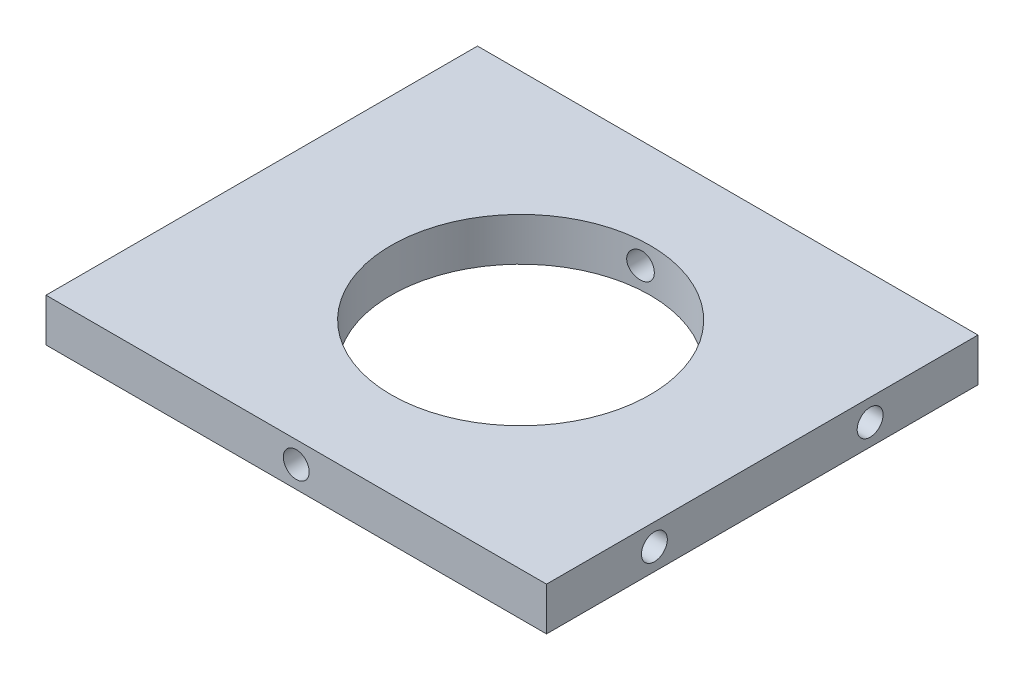
from build123d import *

# Parameters (mm, degrees)
ESQUISSE1_W             = 58
ESQUISSE1_H             = 5
BOSS_EXTRU_1_DEPTH      = 50
ESQUISSE2_R             = 15
ENL_V_MAT_EXTRU_1_DEPTH = 6
ESQUISSE3_R             = 1.5
ENL_V_MAT_EXTRU_2_DEPTH = 10
ESQUISSE4_R             = 1.5
ENL_V_MAT_EXTRU_3_DEPTH = 10
ESQUISSE5_R             = 1.5
ENL_V_MAT_EXTRU_4_DEPTH = 51


with BuildPart() as part:
    # Esquisse1 → Boss.-Extru.1 (new body)
    with BuildSketch(Plane.XY):
        with Locations((23.5, -47.5)):
            Rectangle(ESQUISSE1_W, ESQUISSE1_H)
    extrude(amount=BOSS_EXTRU_1_DEPTH)

    # Esquisse2 → Enlèv. mat.-Extru.1 (cut, through all)
    with BuildSketch(Plane(origin=(0, -45, 0), x_dir=(-1, 0, 0), z_dir=(0, 1, 0))):
        with Locations((-24.5, 25)):
            Circle(ESQUISSE2_R)
    extrude(amount=-ENL_V_MAT_EXTRU_1_DEPTH, mode=Mode.SUBTRACT)

    # Esquisse3 → Enlèv. mat.-Extru.2 (cut)
    with BuildSketch(Plane.ZY.offset(5.5)):
        with Locations((12.5, -47.5)):
            Circle(ESQUISSE3_R)
        with Locations((37.5, -47.5)):
            Circle(ESQUISSE3_R)
    extrude(amount=-ENL_V_MAT_EXTRU_2_DEPTH, mode=Mode.SUBTRACT)

    # Esquisse4 → Enlèv. mat.-Extru.3 (cut)
    with BuildSketch(Plane(origin=(52.5, 0, 0), x_dir=(0, 0, -1), z_dir=(1, 0, 0))):
        with Locations((-37.5, -47.5)):
            Circle(ESQUISSE4_R)
        with Locations((-12.5, -47.5)):
            Circle(ESQUISSE4_R)
    extrude(amount=-ENL_V_MAT_EXTRU_3_DEPTH, mode=Mode.SUBTRACT)

    # Esquisse5 → Enlèv. mat.-Extru.4 (cut, through all)
    with BuildSketch(Plane.XY.offset(50)):
        with Locations((23.5, -47.5)):
            Circle(ESQUISSE5_R)
    extrude(amount=-ENL_V_MAT_EXTRU_4_DEPTH, mode=Mode.SUBTRACT)


solid = part.part
